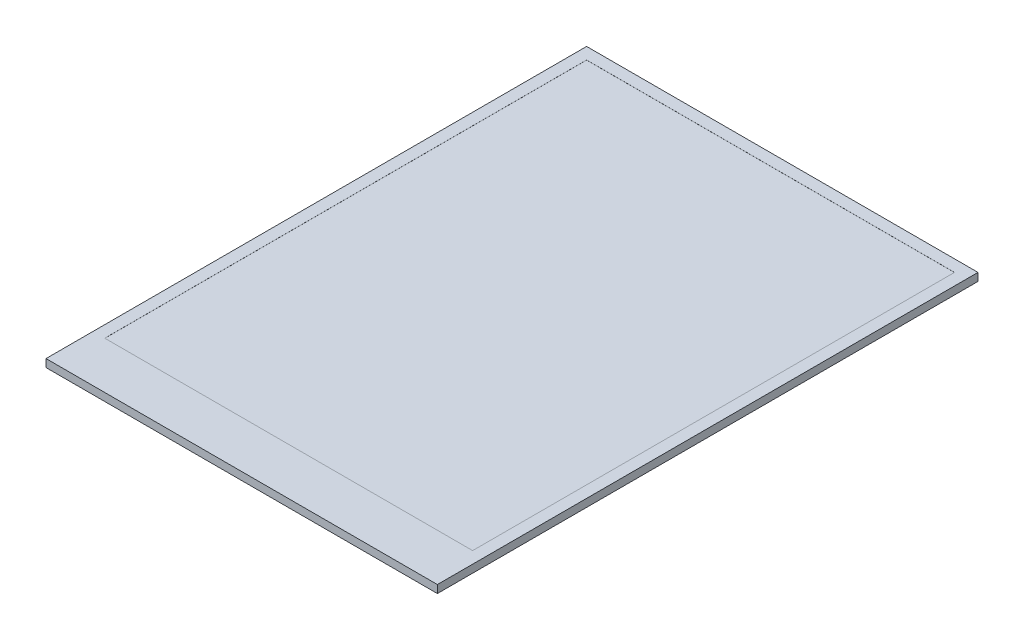
from build123d import *

# Parameters (mm, degrees)
SKETCH1_W           = 49.96
SKETCH1_H           = 69.01
BOSS_EXTRUDE1_DEPTH = 1
SKETCH2_W           = 46.96
SKETCH2_H           = 61.51
CUT_EXTRUDE1_DEPTH  = 0.01


with BuildPart() as part:
    # Sketch1 → Boss-Extrude1 (new body)
    with BuildSketch(Plane(origin=(0, 0, 0), x_dir=(1, 0, 0), z_dir=(0, 1, 0))):
        with Locations((24.98, -34.505)):
            Rectangle(SKETCH1_W, SKETCH1_H)
    extrude(amount=BOSS_EXTRUDE1_DEPTH)

    # Sketch2 → Cut-Extrude1 (cut)
    with BuildSketch(Plane(origin=(0, 1, 0), x_dir=(1, 0, 0), z_dir=(0, 1, 0))):
        with Locations((24.98, -32.255)):
            Rectangle(SKETCH2_W, SKETCH2_H)
    extrude(amount=-CUT_EXTRUDE1_DEPTH, mode=Mode.SUBTRACT)


solid = part.part
